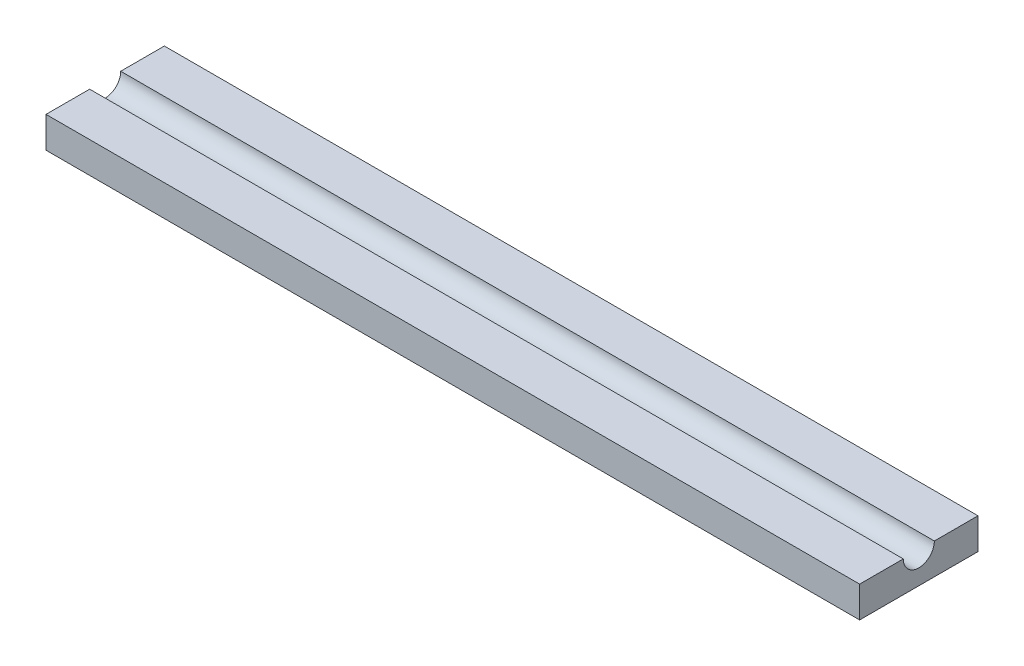
from build123d import *

# Parameters (mm, degrees)
SKETCH1_W           = 261.9
SKETCH1_H           = 38.1
BOSS_EXTRUDE1_DEPTH = 10
SKETCH2_R           = 5
CUT_EXTRUDE1_DEPTH  = 261.9


with BuildPart() as part:
    # Sketch1 → Boss-Extrude1 (new body)
    with BuildSketch(Plane(origin=(0, 0, 0), x_dir=(1, 0, 0), z_dir=(0, 1, 0))):
        with Locations((48.97258547, 0.564444444)):
            Rectangle(SKETCH1_W, SKETCH1_H)
    extrude(amount=BOSS_EXTRUDE1_DEPTH)

    # Sketch2 → Cut-Extrude1 (cut)
    with BuildSketch(Plane(origin=(179.92258547, 0, 0), x_dir=(0, 0, -1), z_dir=(1, 0, 0))):
        with Locations((0.564444444, 10)):
            Circle(SKETCH2_R)
    extrude(amount=-CUT_EXTRUDE1_DEPTH, mode=Mode.SUBTRACT)


solid = part.part
